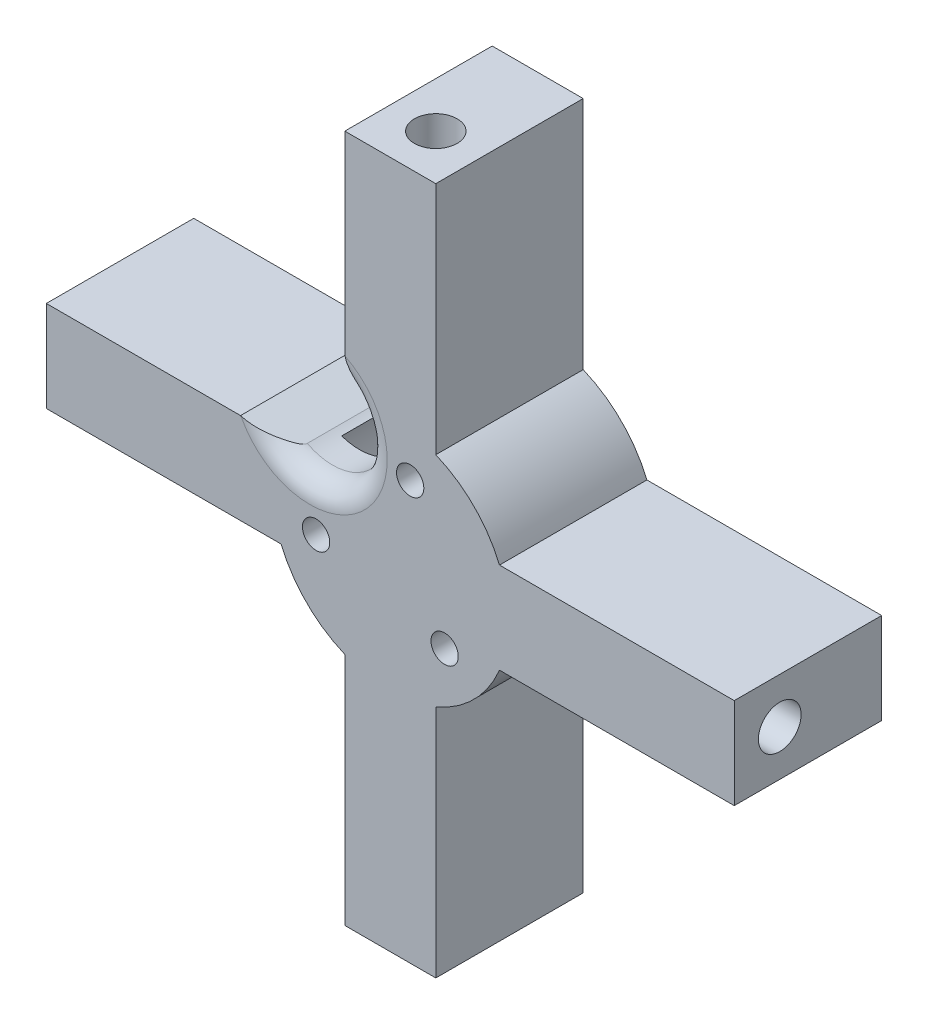
from build123d import *

# Parameters (mm, degrees)
BOSS_EXTRUDE1_DEPTH     = 22.7
SKETCH5_R               = 1.5
CUT_EXTRUDE1_DEPTH      = 70
CUT_EXTRUDE3_DEPTH      = 17.25
CUT_EXTRUDE3_DEPTH_BACK = 17.25
SKETCH6_R               = 11.25
SKETCH7_R               = 2
CUT_EXTRUDE4_DEPTH      = 3
CUT_EXTRUDE5_DEPTH      = 58
CUT_EXTRUDE5_DEPTH_BACK = 66
SKETCH8_W               = 6.5
SKETCH8_H               = 75.6
SKETCH9_R               = 2.35
SKETCH9_R_2             = 1.55
CUT_EXTRUDE7_DEPTH      = 4
SKETCH9_3_R             = 1.55
CUT_EXTRUDE20_DEPTH     = 12
SKETCH21_R              = 2.35
SKETCH21_R_2            = 1.55
CUT_EXTRUDE22_DEPTH     = 4
SKETCH21_2_R            = 1.55
CUT_EXTRUDE23_DEPTH     = 12
CUT_EXTRUDE24_START     = -4
SKETCH19_R              = 2.35
SKETCH19_R_2            = 1.55
CUT_EXTRUDE24_DEPTH     = 4
CUT_EXTRUDE25_START     = -12
SKETCH19_2_R            = 1.55
CUT_EXTRUDE25_DEPTH     = 12
CUT_EXTRUDE26_START     = -4
SKETCH20_R              = 2.35
SKETCH20_R_2            = 1.55
CUT_EXTRUDE26_DEPTH     = 4
CUT_EXTRUDE27_START     = -12
SKETCH20_2_R            = 1.55
CUT_EXTRUDE27_DEPTH     = 12
FILLET2_R               = 2.5
BOSS_EXTRUDE2_DEPTH     = 0.5


with BuildPart() as part:
    # Sketch4 → Boss-Extrude1 (new body)
    with BuildSketch(Plane.XY):
        with BuildLine():
            Line((-5, 37.8), (-5, 12))
            ThreePointArc((-5, 12), (-9.192388155, 9.192388155), (-12, 5))
            Line((-12, 5), (-37.8, 5))
            Line((-37.8, 5), (-37.8, -5))
            Line((-37.8, -5), (-12, -5))
            ThreePointArc((-12, -5), (-9.192388155, -9.192388155), (-5, -12))
            Line((-5, -12), (-5, -37.8))
            Line((-5, -37.8), (5, -37.8))
            Line((5, -37.8), (5, -12))
            ThreePointArc((5, -12), (9.192388155, -9.192388155), (12, -5))
            Line((12, -5), (37.8, -5))
            Line((37.8, -5), (37.8, 5))
            Line((37.8, 5), (12, 5))
            ThreePointArc((12, 5), (9.192388155, 9.192388155), (5, 12))
            Line((5, 12), (5, 37.8))
            Line((5, 37.8), (-5, 37.8))
        make_face()
    extrude(amount=-BOSS_EXTRUDE1_DEPTH)

    # Sketch5 → Cut-Extrude1 (cut)
    with BuildSketch(Plane.XY):
        with Locations((2.184887392, 8.154110756)):
            Circle(SKETCH5_R)
        with Locations((-8.154110756, -2.184887392)):
            Circle(SKETCH5_R)
        with Locations((5.969223364, -5.969223364)):
            Circle(SKETCH5_R)
        with BuildLine():
            Line((-5, 16.456455054), (-3.523070126, 11.621395871))
            ThreePointArc((-3.523070126, 11.621395871), (-4.596194078, 4.596194078), (-11.621395871, 3.523070126))
            Line((-11.621395871, 3.523070126), (-16.456455054, 5))
            Line((-16.456455054, 5), (-14.526937175, 6.929517879))
            ThreePointArc((-14.526937175, 6.929517879), (-13.081475452, 13.081475452), (-6.929517879, 14.526937175))
            Line((-6.929517879, 14.526937175), (-5, 16.456455054))
        make_face()
    extrude(amount=-CUT_EXTRUDE1_DEPTH, mode=Mode.SUBTRACT)

    # Sketch6 → Cut-Extrude3 (cut, two sides: drawn at the far end of the back side and taken through both)
    with BuildSketch(Plane(origin=(0, 0, -22.7), x_dir=(-1, 0, 0), z_dir=(0, 0, -1)).offset(-CUT_EXTRUDE3_DEPTH_BACK)):
        Circle(SKETCH6_R)
    extrude(amount=CUT_EXTRUDE3_DEPTH + CUT_EXTRUDE3_DEPTH_BACK, mode=Mode.SUBTRACT)

    # Sketch7 → Cut-Extrude4 (cut)
    with BuildSketch(Plane(origin=(0, 0, -5.45), x_dir=(-1, 0, 0), z_dir=(0, 0, -1))):
        with Locations((-2.184887392, 8.154110756)):
            Circle(SKETCH7_R)
        with Locations((-5.969223364, -5.969223364)):
            Circle(SKETCH7_R)
        with Locations((8.154110756, -2.184887392)):
            Circle(SKETCH7_R)
    extrude(amount=-CUT_EXTRUDE4_DEPTH, mode=Mode.SUBTRACT)

    # Sketch8 → Cut-Extrude5 (cut, two sides: drawn at the far end of the back side and taken through both)
    with BuildSketch(Plane.ZY.offset(5).offset(-CUT_EXTRUDE5_DEPTH_BACK)):
        with Locations((-19.45, 0)):
            Rectangle(SKETCH8_W, SKETCH8_H)
    extrude(amount=CUT_EXTRUDE5_DEPTH + CUT_EXTRUDE5_DEPTH_BACK, mode=Mode.SUBTRACT)

    # Sketch9 → Cut-Extrude7 (cut)
    with BuildSketch(Plane(origin=(0, 37.8, 0), x_dir=(1, 0, 0), z_dir=(0, 1, 0))):
        with Locations((0, 5)):
            Circle(SKETCH9_R)
        with Locations((0, 5)):
            Circle(SKETCH9_R_2, mode=Mode.SUBTRACT)
    extrude(amount=-CUT_EXTRUDE7_DEPTH, mode=Mode.SUBTRACT)

    # Sketch9_3 → Cut-Extrude20 (cut)
    with BuildSketch(Plane(origin=(0, 37.8, 0), x_dir=(1, 0, 0), z_dir=(0, 1, 0))):
        with Locations((0, 5)):
            Circle(SKETCH9_3_R)
    extrude(amount=-CUT_EXTRUDE20_DEPTH, mode=Mode.SUBTRACT)

    # Sketch21 → Cut-Extrude22 (cut)
    with BuildSketch(Plane.ZY.offset(37.8)):
        with Locations((-5, 0)):
            Circle(SKETCH21_R)
        with Locations((-5, 0)):
            Circle(SKETCH21_R_2, mode=Mode.SUBTRACT)
    extrude(amount=-CUT_EXTRUDE22_DEPTH, mode=Mode.SUBTRACT)

    # Sketch21_2 → Cut-Extrude23 (cut)
    with BuildSketch(Plane.ZY.offset(37.8)):
        with Locations((-5, 0)):
            Circle(SKETCH21_2_R)
    extrude(amount=-CUT_EXTRUDE23_DEPTH, mode=Mode.SUBTRACT)

    # Sketch19 → Cut-Extrude24 (cut)
    with BuildSketch(Plane(origin=(37.8, 0, 0), x_dir=(0, 0, -1), z_dir=(1, 0, 0)).offset(CUT_EXTRUDE24_START)):
        with Locations((5, 0)):
            Circle(SKETCH19_R)
        with Locations((5, 0)):
            Circle(SKETCH19_R_2, mode=Mode.SUBTRACT)
    extrude(amount=CUT_EXTRUDE24_DEPTH, mode=Mode.SUBTRACT)

    # Sketch19_2 → Cut-Extrude25 (cut)
    with BuildSketch(Plane(origin=(37.8, 0, 0), x_dir=(0, 0, -1), z_dir=(1, 0, 0)).offset(CUT_EXTRUDE25_START)):
        with Locations((5, 0)):
            Circle(SKETCH19_2_R)
    extrude(amount=CUT_EXTRUDE25_DEPTH, mode=Mode.SUBTRACT)

    # Sketch20 → Cut-Extrude26 (cut)
    with BuildSketch(Plane.XZ.offset(37.8).offset(CUT_EXTRUDE26_START)):
        with Locations((0, -5)):
            Circle(SKETCH20_R)
        with Locations((0, -5)):
            Circle(SKETCH20_R_2, mode=Mode.SUBTRACT)
    extrude(amount=CUT_EXTRUDE26_DEPTH, mode=Mode.SUBTRACT)

    # Sketch20_2 → Cut-Extrude27 (cut)
    with BuildSketch(Plane.XZ.offset(37.8).offset(CUT_EXTRUDE27_START)):
        with Locations((0, -5)):
            Circle(SKETCH20_2_R)
    extrude(amount=CUT_EXTRUDE27_DEPTH, mode=Mode.SUBTRACT)

    # Fillet2
    fillet2_edges = [part.edges().sort_by_distance(p)[0] for p in [
        (-4.596194078, 4.596194078, 0),
    ]]
    fillet(fillet2_edges, radius=FILLET2_R)

    # Sketch22 → Boss-Extrude2 (add)
    with BuildSketch(Plane(origin=(0, 0, -5.45), x_dir=(-1, 0, 0), z_dir=(0, 0, -1))):
        Polygon((1.099038462, 3.175), (0.814102564, 3.175), (0.814102564, 1.872435897), (-0.814102564, 1.872435897), (-0.814102564, 3.175), (-1.099038462, 3.175), (-1.099038462, 0), (-0.814102564, 0), (-0.814102564, 1.546794872), (0.814102564, 1.546794872), (0.814102564, 0), (1.099038462, 0), align=None)
    extrude(amount=BOSS_EXTRUDE2_DEPTH)


solid = part.part
